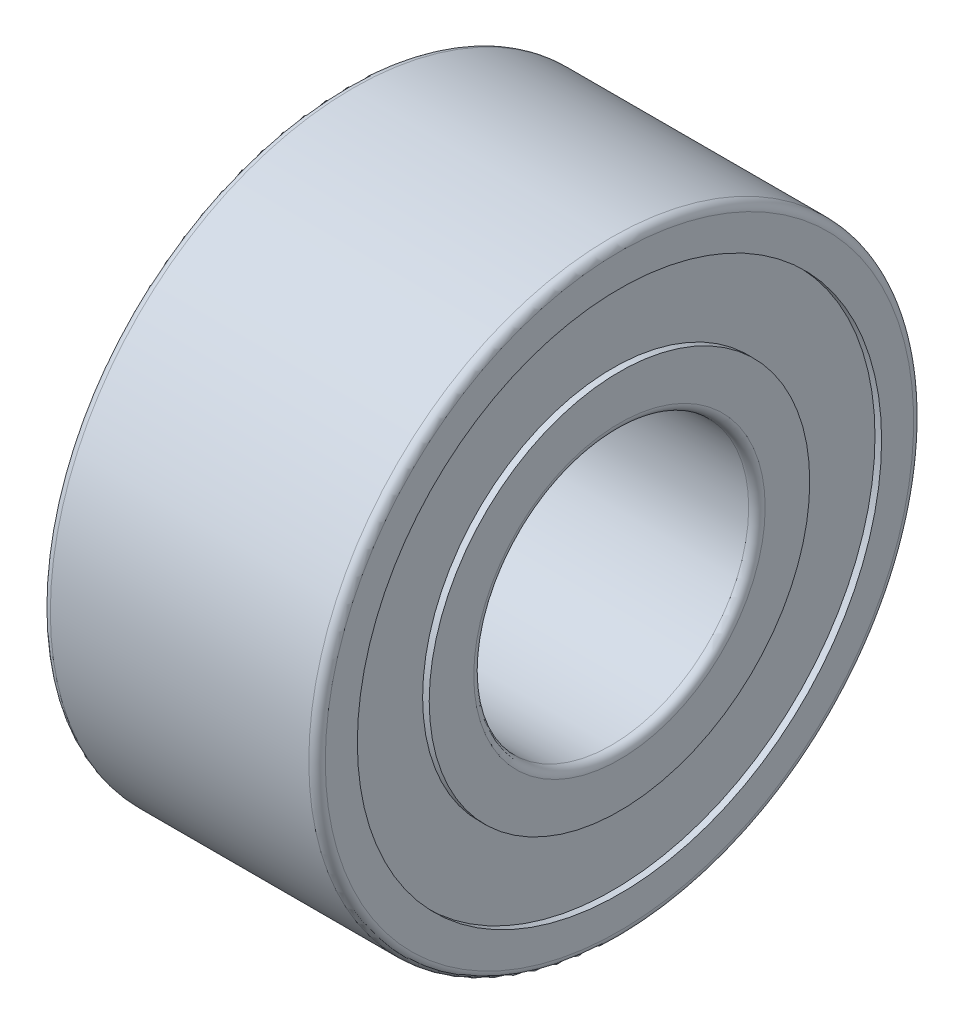
from build123d import *


with BuildPart() as part:
    # Sketch1 → Revolve1 (revolve)
    with BuildSketch(Plane.XY):
        with BuildLine():
            Line((0, 5.35), (0, 4.767))
            Line((0, 4.767), (0.12, 4.767))
            Line((0.12, 4.767), (0.12, 3.46))
            Line((0.12, 3.46), (0, 3.46))
            Line((0, 3.46), (0, 2.65))
            ThreePointArc((0, 2.65), (0.043933983, 2.543933983), (0.15, 2.5))
            Line((0.15, 2.5), (4.85, 2.5))
            ThreePointArc((4.85, 2.5), (4.956066017, 2.543933983), (5, 2.65))
            Line((5, 2.65), (5, 3.46))
            Line((5, 3.46), (4.88, 3.46))
            Line((4.88, 3.46), (4.88, 4.767))
            Line((4.88, 4.767), (5, 4.767))
            Line((5, 4.767), (5, 5.35))
            ThreePointArc((5, 5.35), (4.956066017, 5.456066017), (4.85, 5.5))
            Line((4.85, 5.5), (0.15, 5.5))
            ThreePointArc((0.15, 5.5), (0.043933983, 5.456066017), (0, 5.35))
        make_face()
    revolve(axis=Axis((4.85, 0, 0), (-1, 0, 0)))


solid = part.part
